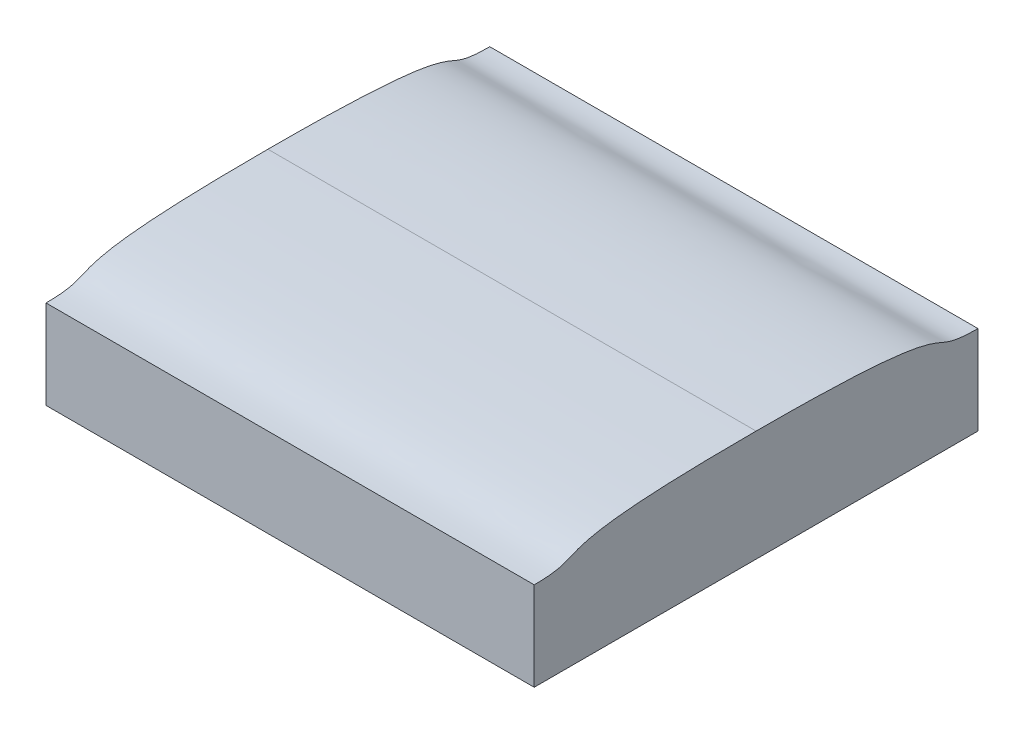
from build123d import *

# Parameters (mm, degrees)
BOSS_EXTRUDE1_DEPTH = 22


with BuildPart() as part:
    # Sketch1 → Boss-Extrude1 (new body)
    with BuildSketch(Plane(origin=(0, 0, 0), x_dir=(0, 0, -1), z_dir=(1, 0, 0))):
        with BuildLine():
            Line((10, -0.230657833), (10, 3.769342167))
            add(Edge.make_bspline(
                [(10, 3.769342167), (7.160129252, 3.769342167), (10.168061659, 4.769342167), (0, 4.769342167)],
                knots=[0, 0, 0, 0, 1, 1, 1, 1], degree=3))
            add(Edge.make_bspline(
                [(-10, 3.769342167), (-7.160129252, 3.769342167), (-10.168061659, 4.769342167), (0, 4.769342167)],
                knots=[0, 0, 0, 0, 1, 1, 1, 1], degree=3))
            Line((-10, 3.769342167), (-10, -0.230657833))
            add(Edge.make_bspline(
                [(-10, -0.230657833), (-5.38988852, -0.230657833), (-8.669092286, -0.230657833), (0, -0.230657833)],
                knots=[0, 0, 0, 0, 1, 1, 1, 1], degree=3))
            add(Edge.make_bspline(
                [(10, -0.230657833), (5.38988852, -0.230657833), (8.669092286, -0.230657833), (0, -0.230657833)],
                knots=[0, 0, 0, 0, 1, 1, 1, 1], degree=3))
        make_face()
    extrude(amount=BOSS_EXTRUDE1_DEPTH)


solid = part.part
